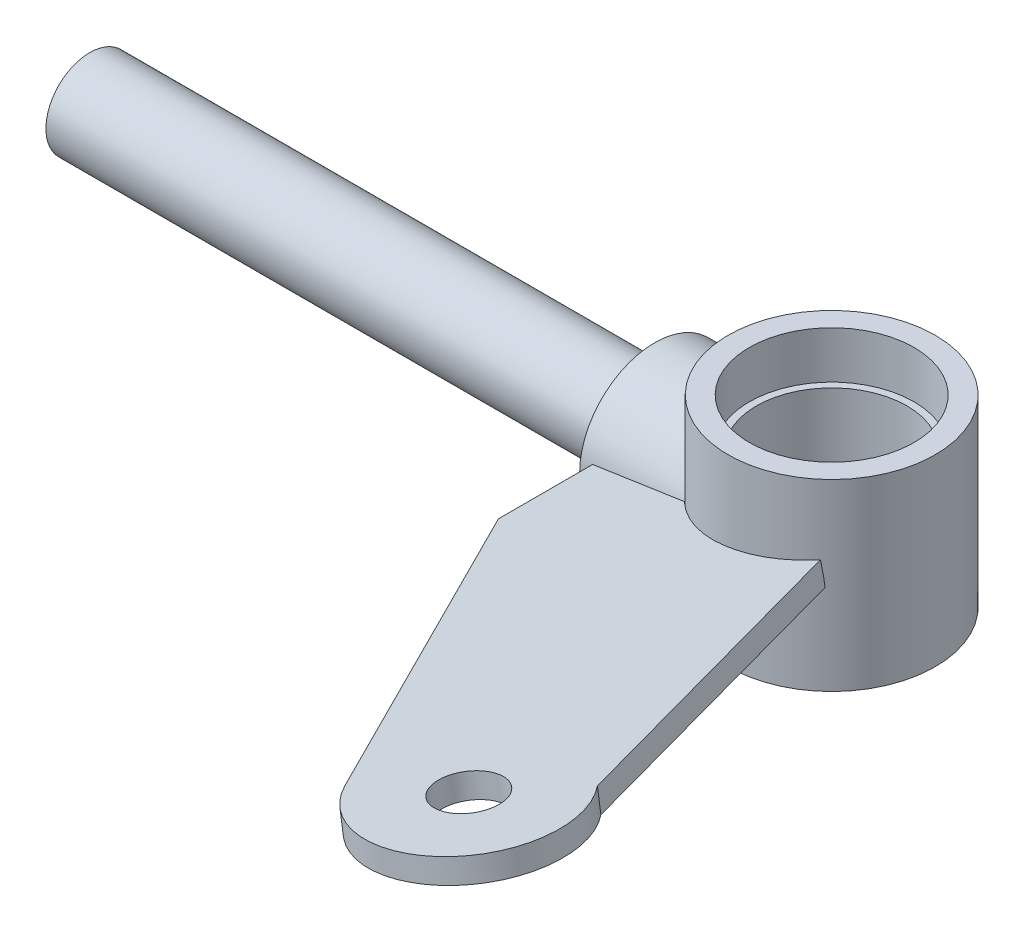
from build123d import *
from build123d.topology import SkipClean

# Parameters (mm, degrees)
SKETCH4_R                            = 4.1275
BOSS_EXTRUDE2_DEPTH                  = 1.5875
BOSS_EXTRUDE2_DEPTH_BACK             = 1.5875
SKETCH5_R                            = 10.130893735
BOSS_EXTRUDE3_DEPTH                  = 9.894953
BOSS_EXTRUDE3_DIRECTION_2_REACH      = 87.304
BOSS_EXTRUDE3_DIRECTION_2_END_RADIUS = 13.97
SKETCH6_R                            = 5.921066373
BOSS_EXTRUDE4_DEPTH                  = 76.2


with BuildPart() as part:
    # Sketch2 → Revolve1 (revolve)
    with BuildSketch(Plane.XY, mode=Mode.PRIVATE) as revolve1_sk:
        Polygon((13.97, 12.3825), (13.97, -12.3825), (11.1125, -12.3825), (11.1125, -6.0325), (10.16, -6.0325), (10.16, 6.0325), (11.1125, 6.0325), (11.1125, 12.3825), align=None)
    revolve(revolve1_sk.sketch.rotate(Axis((0, -12.3825, 0), (0, 1, 0)), 90), axis=Axis((0, -12.3825, 0), (0, 1, 0)))


with BuildPart() as body_2:
    # Sketch4 → Boss-Extrude2 (new, two sides)
    with BuildSketch(Plane(origin=(0, 0, 0), x_dir=(0, 0, -1), z_dir=(-0.14780941112961093, 0.9890158633619168, 0))) as boss_extrude2_sk:
        with BuildLine():
            ThreePointArc((-10.16, 9.588289733), (-13.969031731, 0.164476444), (-10.382944015, -9.346409662))
            Line((-10.382944015, -9.346409662), (-54.039928854, -22.925293076))
            ThreePointArc((-54.039928854, -22.925293076), (-72.254940581, -20.500002013), (-67.999747489, -2.623704278))
            Line((-67.999747489, -2.623704278), (-22.86, 22.098))
            Line((-22.86, 22.098), (-10.16, 22.098))
            Line((-10.16, 22.098), (-10.16, 9.588289733))
        make_face()
        with Locations(Location((-62.0518225, -13.484113782, 0), (0, 0, 90))):
            Circle(SKETCH4_R, mode=Mode.SUBTRACT)
    extrude(amount=BOSS_EXTRUDE2_DEPTH)
    extrude(boss_extrude2_sk.sketch, amount=-BOSS_EXTRUDE2_DEPTH_BACK)


with BuildPart() as body_3:
    # Sketch5 → Boss-Extrude3 (new body)
    with BuildSketch(Plane.ZY.offset(13.97)):
        with Locations((0, -3.566641091)):
            Circle(SKETCH5_R)
    extrude(amount=BOSS_EXTRUDE3_DEPTH)

    # Boss-Extrude3 direction 2: up to this cylinder (the profile starts outside it)
    with SkipClean():  # the faces are left unmerged after this step: merging them gives an invalid solid
        boss_extrude3_direction_2_end = Plane(origin=(0, -3.566641, 0), z_dir=(0, -1, 0)) * Cylinder(BOSS_EXTRUDE3_DIRECTION_2_END_RADIUS, 203.548, mode=Mode.PRIVATE)
        # Sketch5 → Boss-Extrude3 direction 2 (add, up to the surface)
        with BuildSketch(Plane.ZY.offset(13.97), mode=Mode.PRIVATE) as boss_extrude3_direction_2_sk1:
            with Locations((0, -3.566641091)):
                Circle(SKETCH5_R)
        boss_extrude3_direction_2_tool1 = extrude(boss_extrude3_direction_2_sk1.sketch, amount=-BOSS_EXTRUDE3_DIRECTION_2_REACH, mode=Mode.PRIVATE) - boss_extrude3_direction_2_end
        add(boss_extrude3_direction_2_tool1.solids().sort_by_distance((-13.97, -3.566641, 0))[0])
        add(boss_extrude3_direction_2_tool1.solids().sort_by_distance((-13.97, -3.566641, 0))[1])

    # Sketch6 → Boss-Extrude4 (add)
    with BuildSketch(Plane.ZY.offset(23.864952783)):
        with Locations(Location((0, -3.566641091, 0), (0, 0, 180))):
            Circle(SKETCH6_R)
    extrude(amount=BOSS_EXTRUDE4_DEPTH)


solid = Compound([part.part, body_2.part, body_3.part])
